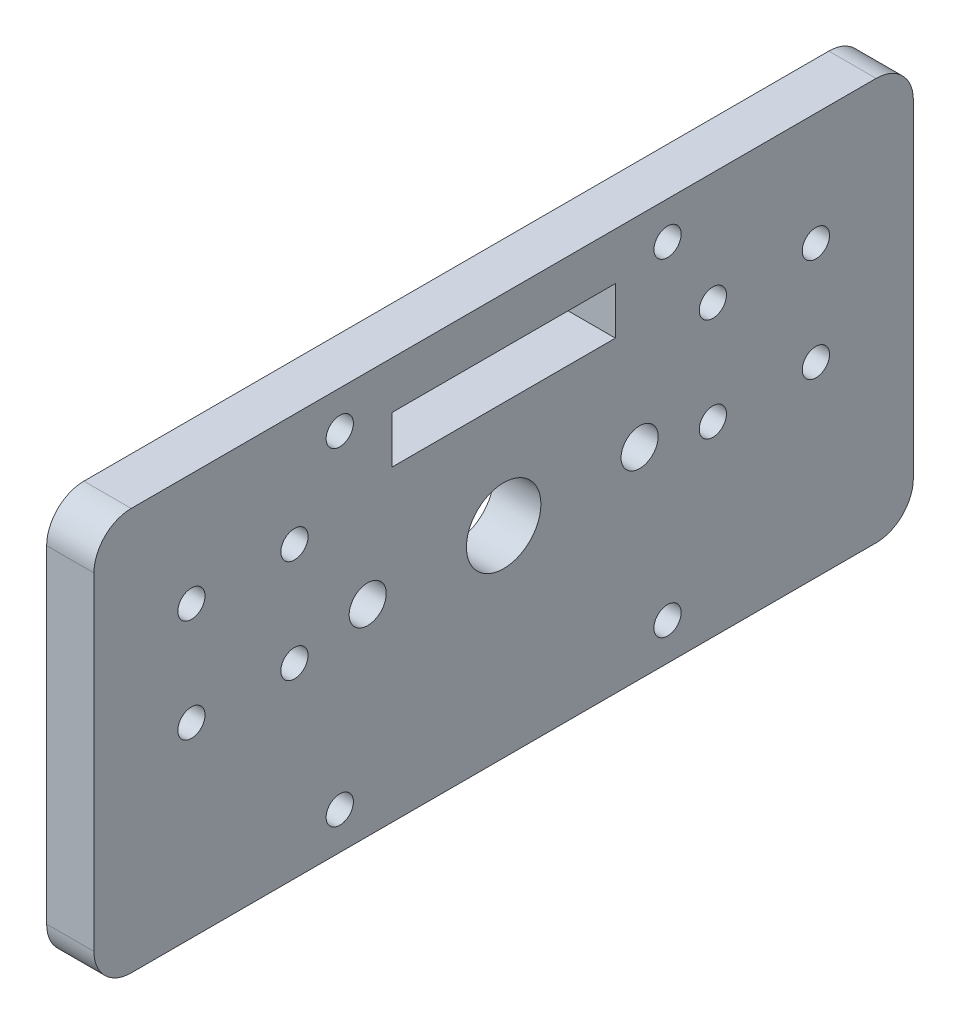
from build123d import *

# Parameters (mm, degrees)
SKETCH1_W              = 110
SKETCH1_H              = 54
BOSS_EXTRUDE1_DEPTH    = 6.35
FILLET1_R              = 5
F_6_CLEARANCE_HOLE1_D  = 3.6576
SKETCH5_R              = 5
CUT_EXTRUDE1_DEPTH     = 7.35
F_6_CLEARANCE_HOLE2_D  = 3.6576
SKETCH10_W             = 30
SKETCH10_H             = 6.35
CUT_EXTRUDE2_DEPTH     = 7.35
F_10_CLEARANCE_HOLE1_D = 4.9784


with BuildPart() as part:
    # Sketch1 → Boss-Extrude1 (new body)
    with BuildSketch(Plane(origin=(0, 0, 0), x_dir=(0, 0, -1), z_dir=(1, 0, 0))):
        Rectangle(SKETCH1_W, SKETCH1_H)
    extrude(amount=BOSS_EXTRUDE1_DEPTH)

    # Fillet1
    fillet1_edges = [part.edges().sort_by_distance(p)[0] for p in [
        (3.175, -27, -55),
        (3.175, -27, 55),
        (3.175, 27, 55),
        (3.175, 27, -55),
    ]]
    fillet(fillet1_edges, radius=FILLET1_R)

    # #6 Clearance Hole1 (through all)
    with Locations(Plane(origin=(6.35, 0, 0), x_dir=(0, 0, -1), z_dir=(1, 0, 0))):
        with Locations((-22, 22), (22, 22), (22, -22), (-22, -22)):
            Hole(F_6_CLEARANCE_HOLE1_D / 2)

    # Sketch5 → Cut-Extrude1 (cut, through all)
    with BuildSketch(Plane(origin=(6.35, 0, 0), x_dir=(0, 0, -1), z_dir=(1, 0, 0))):
        Circle(SKETCH5_R)
    extrude(amount=-CUT_EXTRUDE1_DEPTH, mode=Mode.SUBTRACT)

    # #6 Clearance Hole2 (through all)
    with Locations(Plane(origin=(6.35, 0, 0), x_dir=(0, 0, -1), z_dir=(1, 0, 0))):
        with Locations((-41.914797213, 11.884797213), (-28.085202787, 11.884797213), (-28.085202787, -1.944797213), (-41.914797213, -1.944797213), (28.085202787, 11.884797213), (28.085202787, -1.944797213), (41.914797213, -1.944797213), (41.914797213, 11.884797213)):
            Hole(F_6_CLEARANCE_HOLE2_D / 2)

    # Sketch10 → Cut-Extrude2 (cut, through all)
    with BuildSketch(Plane.ZY):
        with Locations((0, 17.475)):
            Rectangle(SKETCH10_W, SKETCH10_H)
    extrude(amount=-CUT_EXTRUDE2_DEPTH, mode=Mode.SUBTRACT)

    # #10 Clearance Hole1 (through all)
    with Locations(Plane.ZY):
        with Locations((18.25, 0), (-18.25, 0)):
            Hole(F_10_CLEARANCE_HOLE1_D / 2)


solid = part.part
